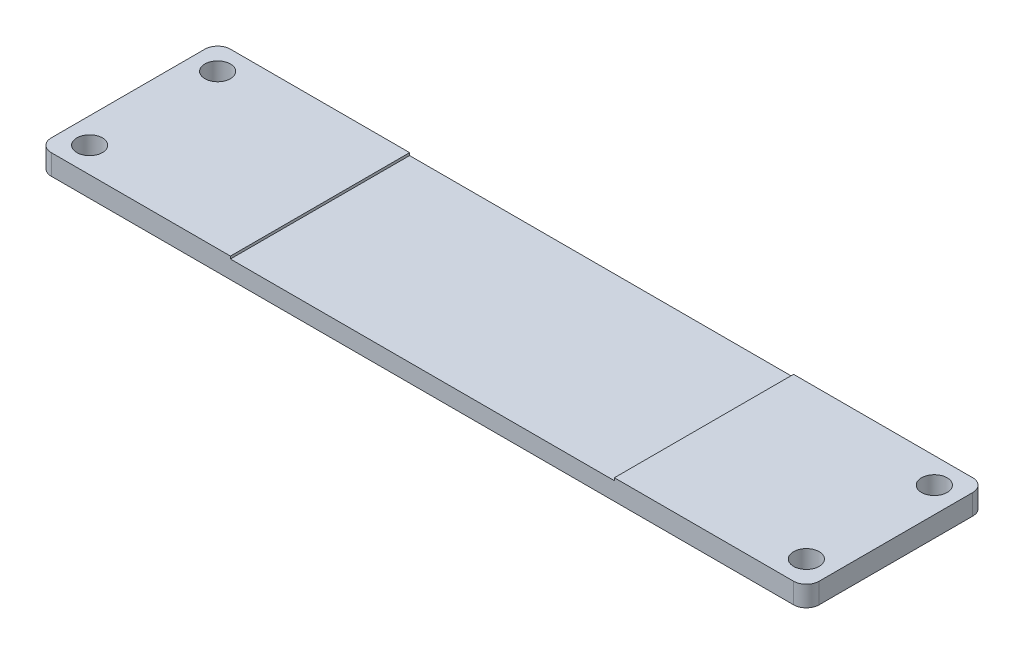
from build123d import *

# Parameters (mm, degrees)
SKETCH_1_W          = 30
SKETCH_1_H          = 7
EXTRUDE_1_DEPTH     = 0.8
SKETCH_2_R          = 0.5
CUT_EXTRUDE_1_DEPTH = 1.8
FILLET_1_R          = 0.5
SKETCH_3_W          = 15
SKETCH_3_H          = 7
CUT_EXTRUDE_2_DEPTH = 0.1


with BuildPart() as part:
    # 草图1 → 凸台-拉伸1 (new body)
    with BuildSketch(Plane(origin=(0, 0, 0), x_dir=(1, 0, 0), z_dir=(0, 1, 0))):
        Rectangle(SKETCH_1_W, SKETCH_1_H)
    extrude(amount=EXTRUDE_1_DEPTH)

    # 草图2 → 切除-拉伸1 (cut, through all)
    with BuildSketch(Plane(origin=(0, 0.8, 0), x_dir=(1, 0, 0), z_dir=(0, 1, 0))):
        with Locations((-14, 2.5)):
            Circle(SKETCH_2_R)
        with Locations((14, 2.5)):
            Circle(SKETCH_2_R)
        with Locations((14, -2.5)):
            Circle(SKETCH_2_R)
        with Locations((-14, -2.5)):
            Circle(SKETCH_2_R)
    extrude(amount=-CUT_EXTRUDE_1_DEPTH, mode=Mode.SUBTRACT)

    # 圆角1
    fillet_1_edges = [part.edges().sort_by_distance(p)[0] for p in [
        (-15, 0.4, -3.5),
        (15, 0.4, -3.5),
        (15, 0.4, 3.5),
        (-15, 0.4, 3.5),
    ]]
    fillet(fillet_1_edges, radius=FILLET_1_R)

    # 草图3 → 切除-拉伸2 (cut)
    with BuildSketch(Plane(origin=(0, 0.8, 0), x_dir=(1, 0, 0), z_dir=(0, 1, 0))):
        Rectangle(SKETCH_3_W, SKETCH_3_H)
    extrude(amount=-CUT_EXTRUDE_2_DEPTH, mode=Mode.SUBTRACT)


solid = part.part
